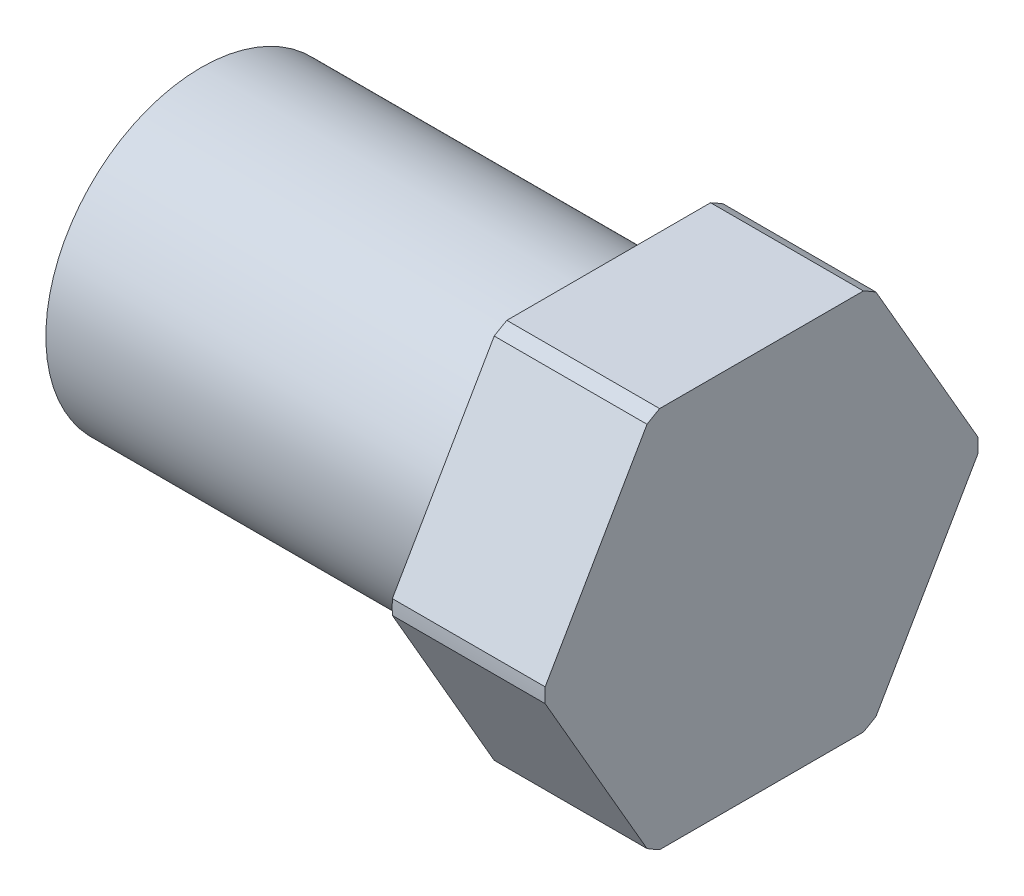
from build123d import *

# Parameters (mm, degrees)
CUT_EXTRUDE1_DEPTH      = 31.730326227
CUT_EXTRUDE1_DEPTH_BACK = 31.730326227
SKETCH2_OUTSIDE_W       = 34.798
SKETCH2_OUTSIDE_H       = 34.798
SKETCH3_R               = 5.55625
CUT_EXTRUDE2_DEPTH      = 32.430896424


with BuildPart() as part:
    # Sketch1 → Revolve1 (revolve)
    with BuildSketch(Plane.XY):
        Polygon((0, 10.795), (-7.62, 10.795), (-7.62, 7.747), (-27.94, 7.747), (-27.94, 0), (19.05, 0), (19.05, 5.55625), (0, 5.55625), align=None)
    revolve(axis=Axis((-27.94, 0, 0), (1, 0, 0)))

    # Sketch2 outside → Cut-Extrude1 (cut, two sides: drawn at the far end of the back side and taken through both)
    with BuildSketch(Plane.ZY.offset(7.62).offset(-CUT_EXTRUDE1_DEPTH_BACK)):
        Rectangle(SKETCH2_OUTSIDE_W, SKETCH2_OUTSIDE_H)
        Polygon((-5.499261314, 9.525), (-10.998522628, 0), (-5.499261314, -9.525), (5.499261314, -9.525), (10.998522628, 0), (5.499261314, 9.525), align=None, mode=Mode.SUBTRACT)
    extrude(amount=CUT_EXTRUDE1_DEPTH + CUT_EXTRUDE1_DEPTH_BACK, mode=Mode.SUBTRACT)

    # Sketch3 → Cut-Extrude2 (cut, through all)
    with BuildSketch(Plane(origin=(0, 0, 0), x_dir=(0, 0, -1), z_dir=(1, 0, 0))):
        Circle(SKETCH3_R)
    extrude(amount=CUT_EXTRUDE2_DEPTH, mode=Mode.SUBTRACT)


solid = part.part
